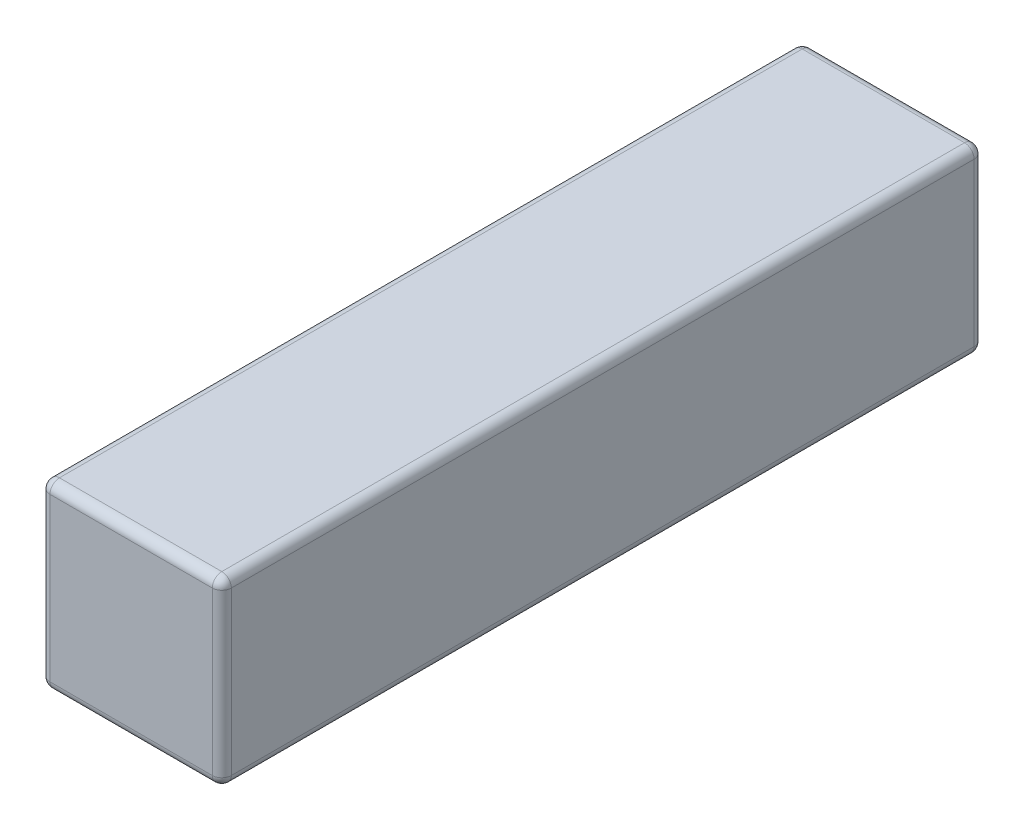
from build123d import *

# Parameters (mm, degrees)
SKETCH1_W           = 9.525
SKETCH1_H           = 9.525
BOSS_EXTRUDE1_DEPTH = 40
FILLET1_R           = 0.5


with BuildPart() as part:
    # Sketch1 → Boss-Extrude1 (new body)
    with BuildSketch(Plane.XY):
        Rectangle(SKETCH1_W, SKETCH1_H)
    extrude(amount=BOSS_EXTRUDE1_DEPTH)

    # Fillet1
    fillet1_edges = [part.edges().sort_by_distance(p)[0] for p in [
        (0, -4.7625, 40),
        (0, -4.7625, 0),
        (4.7625, -4.7625, 20),
        (4.7625, 0, 40),
        (4.7625, 0, 0),
        (-4.7625, 0, 40),
        (-4.7625, -4.7625, 20),
        (-4.7625, 0, 0),
        (4.7625, 4.7625, 20),
        (0, 4.7625, 40),
        (-4.7625, 4.7625, 20),
        (0, 4.7625, 0),
    ]]
    fillet(fillet1_edges, radius=FILLET1_R)


solid = part.part
